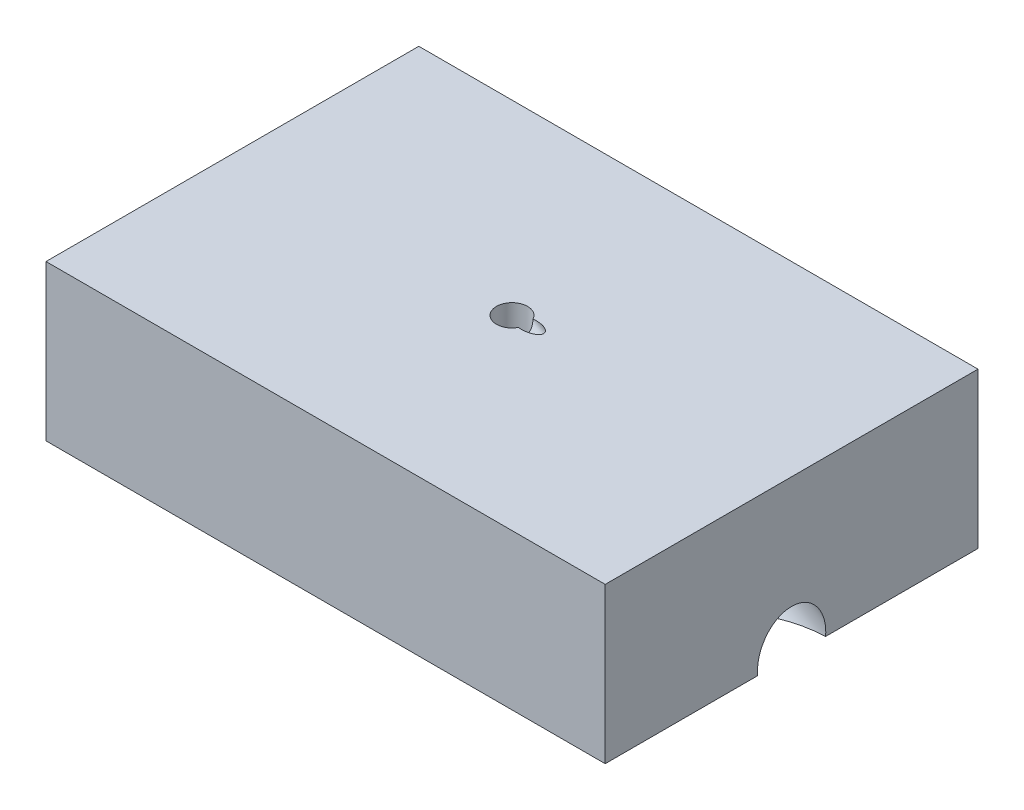
from build123d import *

# Parameters (mm, degrees)
SKETCH2_W                = 90
SKETCH2_H                = 60
BOSS_EXTRUDE1_DEPTH      = 25
SKETCH11_R               = 2.5
CUT_EXTRUDE8_DEPTH       = 5.2
SKETCH17_R               = 6.25
CUT_EXTRUDE14_DEPTH      = 2
SKETCH18_R               = 6.75
CUT_EXTRUDE15_DEPTH      = 18.8
SKETCH20_R               = 5.5
CUT_EXTRUDE17_DEPTH      = 6.21
CUT_EXTRUDE17_DEPTH_BACK = 30
SKETCH26_R               = 1.2
CUT_EXTRUDE20_DEPTH      = 62.241905284


with BuildPart() as part:
    # Sketch2 → Boss-Extrude1 (new body)
    with BuildSketch(Plane(origin=(0, 0, 0), x_dir=(1, 0, 0), z_dir=(0, 1, 0))):
        Rectangle(SKETCH2_W, SKETCH2_H)
    extrude(amount=BOSS_EXTRUDE1_DEPTH)

    # Sketch11 → Cut-Extrude8 (cut)
    with BuildSketch(Plane(origin=(0, 25, 0), x_dir=(1, 0, 0), z_dir=(0, 1, 0))):
        Circle(SKETCH11_R)
    extrude(amount=-CUT_EXTRUDE8_DEPTH, mode=Mode.SUBTRACT)

    # Sketch17 → Cut-Extrude14 (cut)
    with BuildSketch(Plane(origin=(0, 19.8, 0), x_dir=(1, 0, 0), z_dir=(0, 1, 0))):
        Circle(SKETCH17_R)
    extrude(amount=-CUT_EXTRUDE14_DEPTH, mode=Mode.SUBTRACT)

    # Sketch18 → Cut-Extrude15 (cut, through all)
    with BuildSketch(Plane(origin=(0, 17.8, 0), x_dir=(1, 0, 0), z_dir=(0, 1, 0))):
        Circle(SKETCH18_R)
    extrude(amount=-CUT_EXTRUDE15_DEPTH, mode=Mode.SUBTRACT)

    # Sketch20 → Cut-Extrude17 (cut, two sides)
    with BuildSketch(Plane(origin=(13.839745962, -7.990381057, 0), x_dir=(0, 0, 1), z_dir=(-0.866025404, 0.5, 0))) as cut_extrude17_sk:
        with Locations((0, 23)):
            Circle(SKETCH20_R)
    extrude(amount=CUT_EXTRUDE17_DEPTH, mode=Mode.SUBTRACT)
    extrude(cut_extrude17_sk.sketch, amount=-CUT_EXTRUDE17_DEPTH_BACK, mode=Mode.SUBTRACT)

    # Sketch26 → Cut-Extrude20 (cut, through all)
    with BuildSketch(Plane(origin=(8.461728205, -4.885381057, 0), x_dir=(0, 0, -1), z_dir=(0.866025404, -0.5, 0))):
        with Locations((0, 23)):
            Circle(SKETCH26_R)
    extrude(amount=-CUT_EXTRUDE20_DEPTH, mode=Mode.SUBTRACT)


solid = part.part
